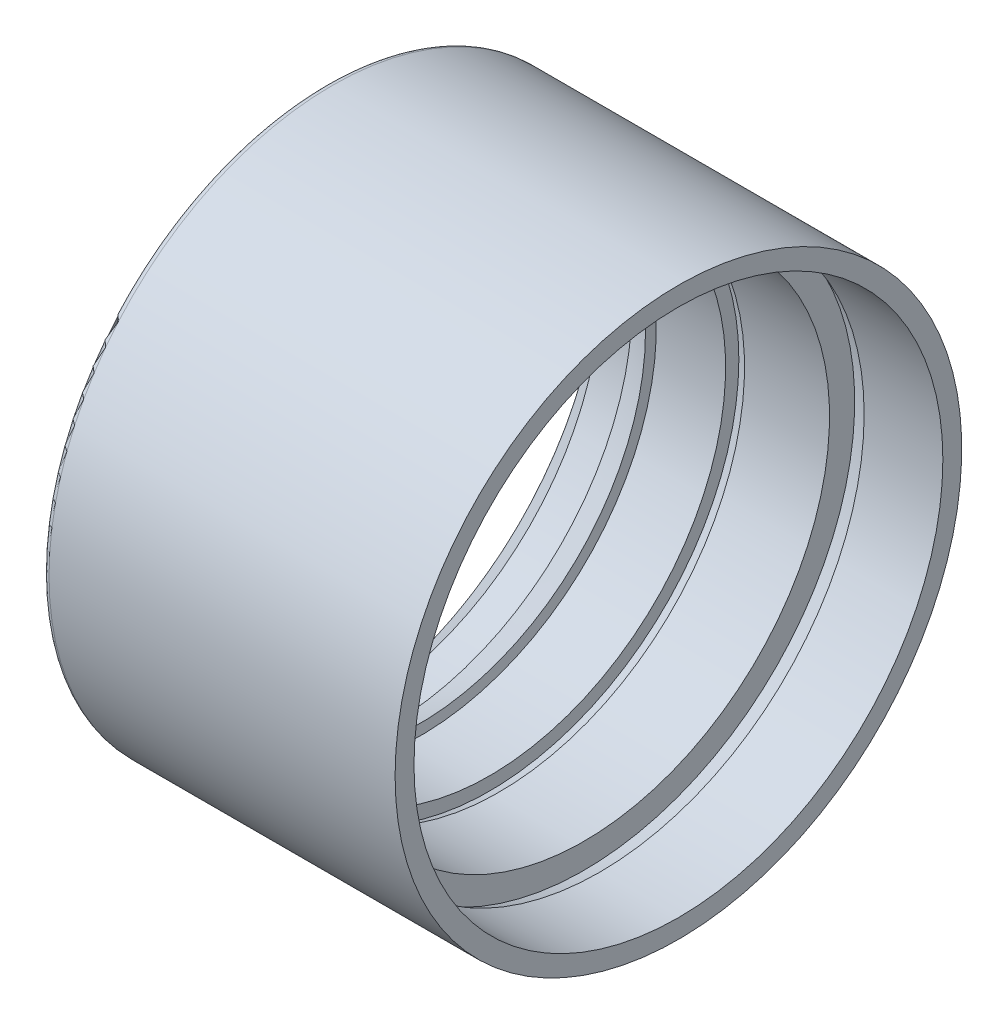
from build123d import *

# Parameters (mm, degrees)
ZAOBLIT1_R = 1


with BuildPart() as part:
    # Skica1 → Rotovat1 (revolve)
    with BuildSketch(Plane.XY):
        with BuildLine():
            Line((-41.226629622, 36), (-45.875032134, 38.5))
            Line((-45.875032134, 38.5), (-50.875032134, 38.5))
            Line((-50.875032134, 38.5), (-57.375032134, 45))
            Line((-57.375032134, 45), (0, 45))
            Line((0, 45), (0, 42))
            Line((0, 42), (-12.5, 42))
            Line((-12.5, 42), (-15, 43))
            Line((-15, 43), (-15, 39))
            Line((-15, 39), (-28.5, 39))
            Line((-28.5, 39), (-30, 39.6))
            Line((-30, 39.6), (-30, 37.5))
            Line((-30, 37.5), (-41, 37.5))
            ThreePointArc((-41, 37.5), (-41.114471082, 36.750174697), (-41.226629622, 36))
        make_face()
    revolve(axis=Axis((0, 0, 0), (1, 0, 0)))

    # Zaoblit1
    zaoblit1_edges = [part.edges().sort_by_distance(p)[0] for p in [
        (-57.375032134, -45, 0),
    ]]
    fillet(zaoblit1_edges, radius=ZAOBLIT1_R)


solid = part.part
